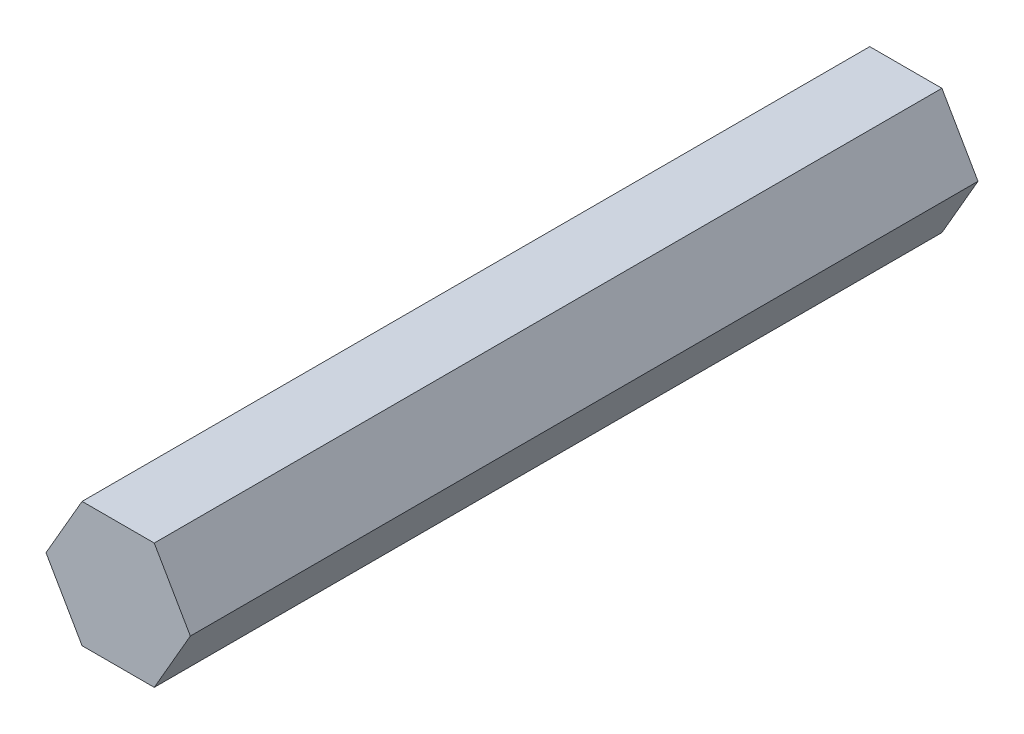
from build123d import *

# Parameters (mm, degrees)
BOSS_EXTRUDE1_DEPTH = 80


with BuildPart() as part:
    # Sketch1 → Boss-Extrude1 (new body)
    with BuildSketch(Plane.XY):
        Polygon((-3.665, 6.34796621), (-7.33, 0), (-3.665, -6.34796621), (3.665, -6.34796621), (7.33, 0), (3.665, 6.34796621), align=None)
    extrude(amount=BOSS_EXTRUDE1_DEPTH)


solid = part.part
